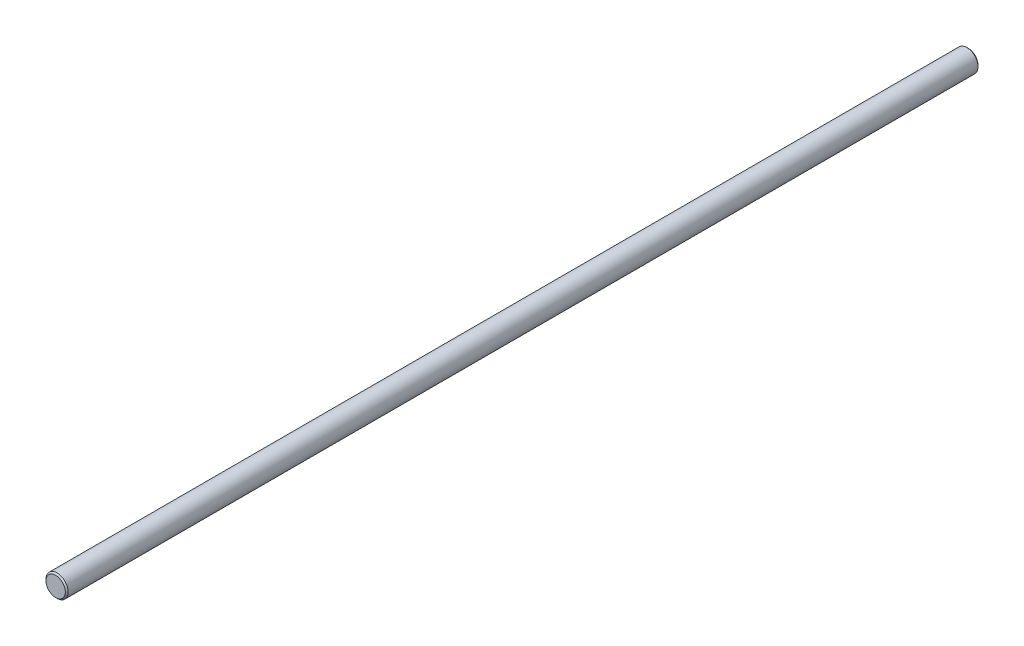
from build123d import *

# Parameters (mm, degrees)
SKETCH1_R           = 4
BOSS_EXTRUDE1_DEPTH = 330
CHAMFER1_SIZE       = 0.5


with BuildPart() as part:
    # Sketch1 → Boss-Extrude1 (new body)
    with BuildSketch(Plane.XY):
        Circle(SKETCH1_R)
    extrude(amount=-BOSS_EXTRUDE1_DEPTH)

    # Chamfer1
    chamfer1_edges = [part.edges().sort_by_distance(p)[0] for p in [
        (-4, 0, 0),
        (-4, 0, -330),
    ]]
    chamfer(chamfer1_edges, length=CHAMFER1_SIZE)


solid = part.part
